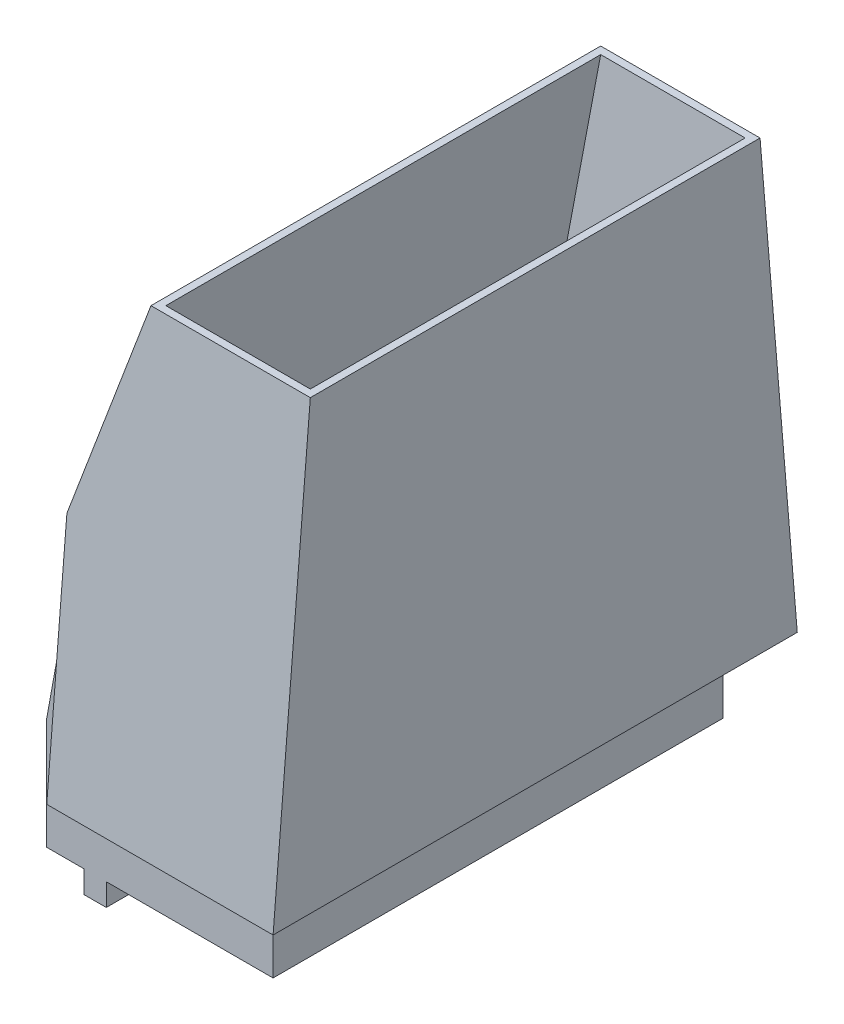
from build123d import *

# Parameters (mm, degrees)
AUFSATZ_LINEAR_AUSTRAGEN1_DEPTH      = 60.4
AUFSATZ_LINEAR_AUSTRAGEN2_DEPTH      = 30.4
AUFSATZ_LINEAR_AUSTRAGEN3_DEPTH      = 55.2
AUFSATZ_LINEAR_AUSTRAGEN3_DEPTH_BACK = 5.2
SKIZZE4_W                            = 5
SKIZZE4_H                            = 10
SCHNITT_LINEAR_AUSTRAGEN1_DEPTH      = 66.4
SCHNITT_LINEAR_AUSTRAGEN4_DEPTH      = 6
SCHNITT_LINEAR_AUSTRAGEN4_DEPTH_BACK = 66.4


with BuildPart() as part:
    # Skizze1 → Aufsatz-Linear austragen1 (new body)
    with BuildSketch(Plane.XY):
        Polygon((14, 14.875), (14, 29.875), (23, 84.875), (24, 84.875), (24, 24.875), (19, 24.875), (19, 14.875), align=None)
    extrude(amount=AUFSATZ_LINEAR_AUSTRAGEN1_DEPTH)

    # Skizze2 → Aufsatz-Linear austragen2 (add)
    with BuildSketch(Plane(origin=(24, 0, 0), x_dir=(0, 0, -1), z_dir=(1, 0, 0))):
        Polygon((-59.4, 84.875), (-60.4, 84.875), (-65.4, 24.875), (-60.4, 24.875), (-60.4, 14.875), (-55.2, 14.875), (-55.2, 29.875), align=None)
        Polygon((0, 24.875), (0, 14.875), (-5.2, 14.875), (-5.2, 29.875), (-1, 84.875), (0, 84.875), (5, 24.875), align=None)
    extrude(amount=-AUFSATZ_LINEAR_AUSTRAGEN2_DEPTH)

    # Skizze3 → Aufsatz-Linear austragen3 (add, two sides)
    with BuildSketch(Plane.XY.offset(5.2)) as aufsatz_linear_austragen3_sk:
        Polygon((-3.4, 29.875), (-3.4, 14.875), (-3.4, 11.875), (-6.4, 11.875), (-6.4, 14.875), (-11.4, 14.875), (-11.4, 29.875), (-1.4, 84.875), (3.6, 84.875), align=None)
    extrude(amount=AUFSATZ_LINEAR_AUSTRAGEN3_DEPTH)
    extrude(aufsatz_linear_austragen3_sk.sketch, amount=-AUFSATZ_LINEAR_AUSTRAGEN3_DEPTH_BACK)

    # Skizze4 → Schnitt-Linear austragen1 (cut, through all)
    with BuildSketch(Plane.XY.offset(60.4)):
        with Locations((21.5, 19.875)):
            Rectangle(SKIZZE4_W, SKIZZE4_H)
    extrude(amount=-SCHNITT_LINEAR_AUSTRAGEN1_DEPTH, mode=Mode.SUBTRACT)

    # Skizze7 → Schnitt-Linear austragen4 (cut, two sides)
    with BuildSketch(Plane(origin=(0, 0, 0), x_dir=(-1, 0, 0), z_dir=(0, 0, -1))) as schnitt_linear_austragen4_sk:
        Polygon((6.4, 57.375), (-2.6, 84.875), (6.4, 84.875), align=None)
    extrude(amount=SCHNITT_LINEAR_AUSTRAGEN4_DEPTH, mode=Mode.SUBTRACT)
    extrude(schnitt_linear_austragen4_sk.sketch, amount=-SCHNITT_LINEAR_AUSTRAGEN4_DEPTH_BACK, mode=Mode.SUBTRACT)


solid = part.part
